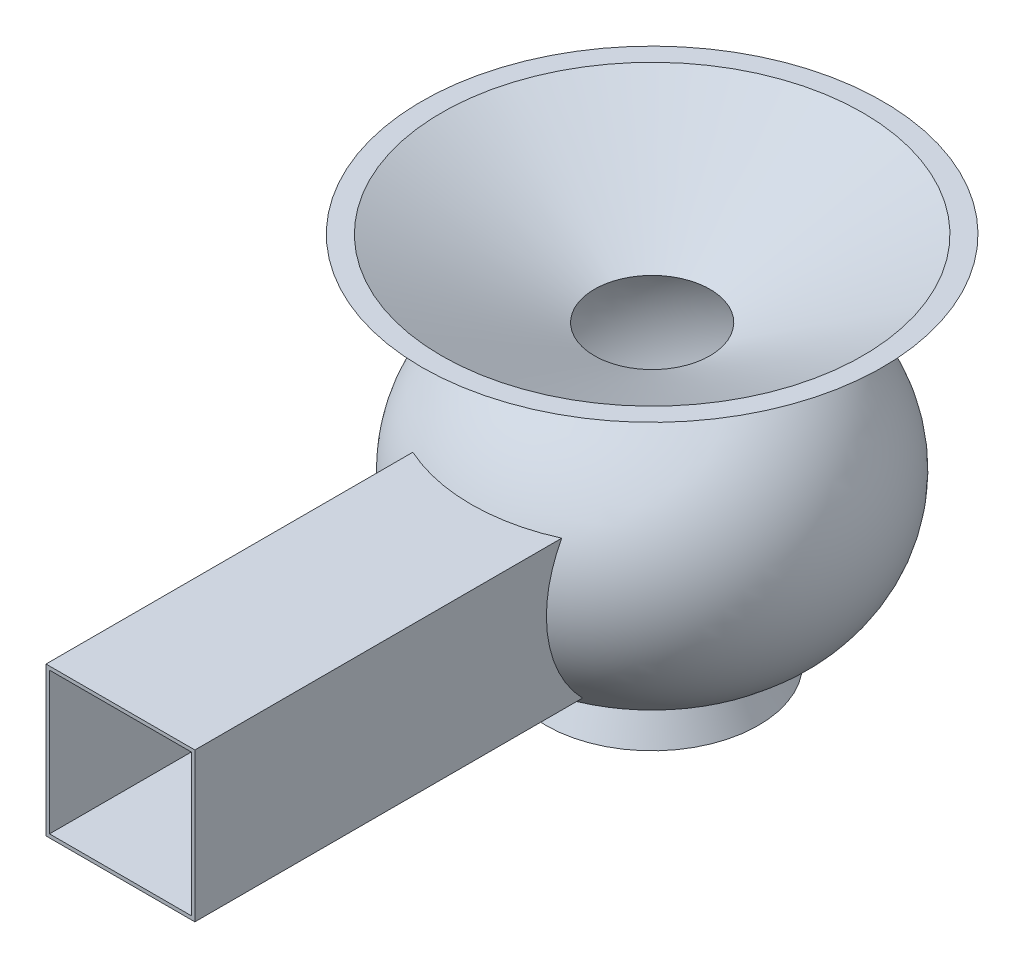
from build123d import *

# Parameters (mm, degrees)
BOSS_EXTRUDE1_REACH = 432
SKETCH2_W           = 84
SKETCH2_H           = 84
CUT_EXTRUDE2_REACH  = 432
SKETCH4_W           = 80
SKETCH4_H           = 80


with BuildPart() as part:
    # Sketch1 → Revolve3 (revolve)
    with BuildSketch(Plane.XY):
        with BuildLine():
            Line((42.537819259, 23.744021594), (51.909830056, 5))
            Line((51.909830056, 5), (0, 5))
            Line((0, 5), (0, 0))
            Line((0, 0), (60, 0))
            Line((60, 0), (50, 20))
            ThreePointArc((50, 20), (110, 95), (50, 170))
            Line((50, 170), (130, 210))
            Line((130, 210), (118.819660113, 210))
            Line((118.819660113, 210), (32.565301615, 166.872820751))
            ThreePointArc((32.565301615, 166.872820751), (104.826169616, 99.995788292), (42.537819259, 23.744021594))
        make_face()
    revolve(axis=Axis((0, 220.652020313, 0), (0, -1, 0)))

    # Sketch2 → Boss-Extrude1 (add, up to next)
    with BuildSketch(Plane.XY.offset(300), mode=Mode.PRIVATE) as boss_extrude1_sk1:
        with Locations((0, 87)):
            Rectangle(SKETCH2_W, SKETCH2_H)
    boss_extrude1_tool1 = extrude(boss_extrude1_sk1.sketch, amount=-BOSS_EXTRUDE1_REACH, mode=Mode.PRIVATE) - part.part
    add(boss_extrude1_tool1.solids().sort_by_distance((0, 87, 300))[0])

    # Sketch4 → Cut-Extrude2 (cut, up to next)
    with BuildSketch(Plane.XY.offset(300), mode=Mode.PRIVATE) as cut_extrude2_sk1:
        with Locations((0, 87)):
            Rectangle(SKETCH4_W, SKETCH4_H)
    cut_extrude2_tool1 = extrude(cut_extrude2_sk1.sketch, amount=-CUT_EXTRUDE2_REACH, mode=Mode.PRIVATE) & part.part
    add(cut_extrude2_tool1.solids().sort_by_distance((0, 87, 300))[0], mode=Mode.SUBTRACT)


solid = part.part
